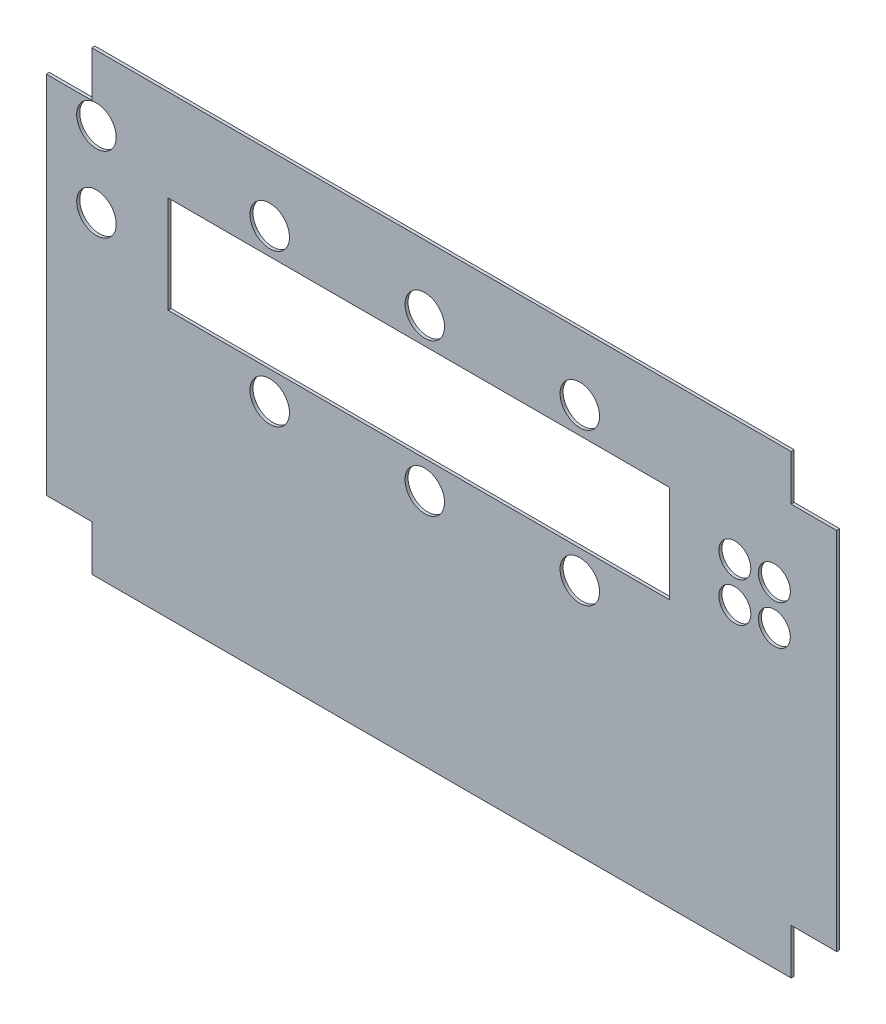
from build123d import *

# Parameters (mm, degrees)
EXTRUDE1_DEPTH        = 1
SKETCH2_W             = 165
SKETCH2_H             = 32
CUT_EXTRUDE1_DEPTH    = 1
SKETCH3_R             = 6.5
SKETCH3_R_2           = 5.25
CORTE_EXTRUS_O1_DEPTH = 2


with BuildPart() as part:
    # Sketch1 → Extrude1 (new body)
    with BuildSketch(Plane.XY):
        Polygon((-115, 75), (115, 75), (115, 60), (130, 60), (130, -60), (115, -60), (115, -75), (-115, -75), (-115, -60), (-130, -60), (-130, 60), (-115, 60), align=None)
    extrude(amount=EXTRUDE1_DEPTH)

    # Sketch2 → Cut-Extrude1 (cut)
    with BuildSketch(Plane.XY.offset(1)):
        with Locations((-7.5, 28.75)):
            Rectangle(SKETCH2_W, SKETCH2_H)
    extrude(amount=-CUT_EXTRUDE1_DEPTH, mode=Mode.SUBTRACT)

    # Sketch3 → Corte-extrusão1 (cut, through all)
    with BuildSketch(Plane.XY.offset(1)):
        with Locations((-113.5, 53.5)):
            Circle(SKETCH3_R)
        with Locations((-113.5, 28.75)):
            Circle(SKETCH3_R)
        with Locations((-56.5, 3.5)):
            Circle(SKETCH3_R)
        with Locations((-5.5, 3.5)):
            Circle(SKETCH3_R)
        with Locations((45.5, 3.5)):
            Circle(SKETCH3_R)
        with Locations((45.5, 53.5)):
            Circle(SKETCH3_R)
        with Locations((-5.5, 53.5)):
            Circle(SKETCH3_R)
        with Locations((-56.5, 53.5)):
            Circle(SKETCH3_R)
        with Locations((96.5, 35)):
            Circle(SKETCH3_R_2)
        with Locations((109.5, 35)):
            Circle(SKETCH3_R_2)
        with Locations((109.5, 22)):
            Circle(SKETCH3_R_2)
        with Locations((96.5, 22)):
            Circle(SKETCH3_R_2)
    extrude(amount=-CORTE_EXTRUS_O1_DEPTH, mode=Mode.SUBTRACT)


solid = part.part
